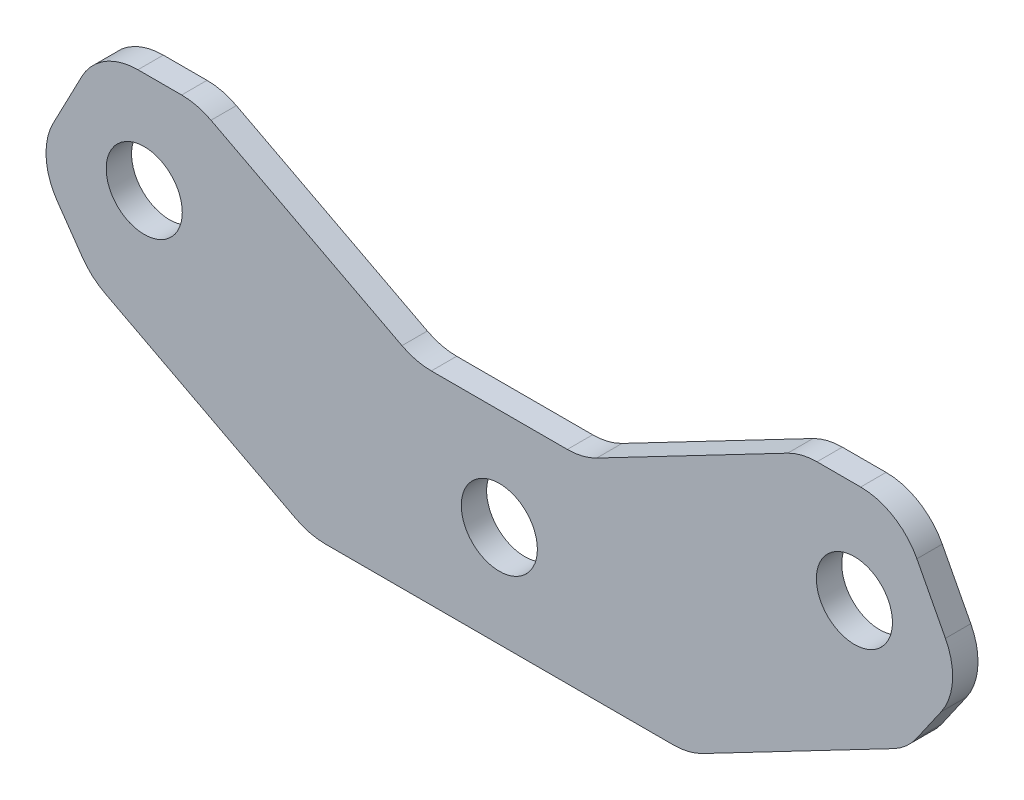
from build123d import *

# Parameters (mm, degrees)
SZKIC1_R                    = 3
DODANIE_WYCI_GNI_CIE1_DEPTH = 2
ZAOKR_GLENIE2_R             = 5


with BuildPart() as part:
    # Szkic1 → Dodanie-wyciągnięcie1 (new body)
    with BuildSketch(Plane.XY):
        Polygon((-6.588738933, 8), (6.588738933, 8), (23.822043257, 17), (31.525212111, 17), (36.579652034, 7.321699847), (32.177956743, 1), (14.944652418, -8), (-14.944652418, -8), (-32.177956743, 1), (-36.579652034, 7.321699847), (-31.525212111, 17), (-23.822043257, 17), align=None)
        Circle(SZKIC1_R, mode=Mode.SUBTRACT)
        with Locations((28, 9)):
            Circle(SZKIC1_R, mode=Mode.SUBTRACT)
        with Locations((-28, 9)):
            Circle(SZKIC1_R, mode=Mode.SUBTRACT)
    extrude(amount=DODANIE_WYCI_GNI_CIE1_DEPTH)

    # Zaokrąglenie2
    zaokr_glenie2_edges = [part.edges().sort_by_distance(p)[0] for p in [
        (6.588738933, 8, 1),
        (23.822043257, 17, 1),
        (31.525212111, 17, 1),
        (36.579652034, 7.321699847, 1),
        (32.177956743, 1, 1),
        (14.944652418, -8, 1),
        (-14.944652418, -8, 1),
        (-32.177956743, 1, 1),
        (-36.579652034, 7.321699847, 1),
        (-31.525212111, 17, 1),
        (-23.822043257, 17, 1),
        (-6.588738933, 8, 1),
    ]]
    fillet(zaokr_glenie2_edges, radius=ZAOKR_GLENIE2_R)


solid = part.part
